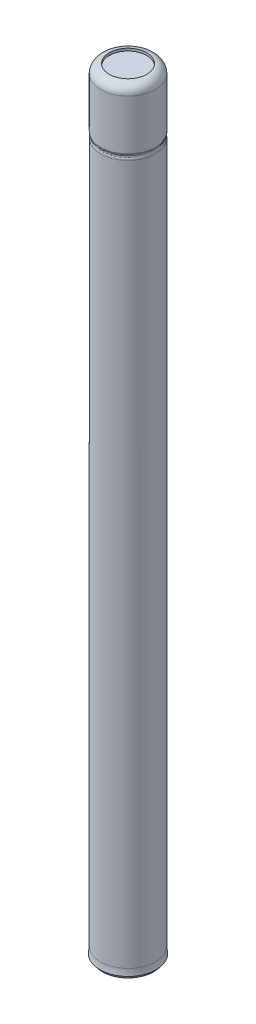
from build123d import *

# Parameters (mm, degrees)
FILLET1_R          = 3
FILLET2_R          = 0.75
SKETCH3_R          = 6.38
CUT_EXTRUDE1_DEPTH = 0.85


with BuildPart() as part:
    # Sketch2 → Revolve1 (revolve)
    with BuildSketch(Plane.XY):
        with BuildLine():
            Line((0, 263.525), (9.34, 263.525))
            Line((9.34, 263.525), (9.34, 243.380049267))
            Line((9.34, 243.380049267), (9.000677154, 242.525))
            Line((9.000677154, 242.525), (9.34, 241.669950733))
            Line((9.34, 241.669950733), (9.34, 3.410583034))
            ThreePointArc((9.34, 3.410583034), (9.391810091, 2.300465987), (9.546789941, 1.2))
            Line((9.546789941, 1.2), (9.000677154, 1.2))
            Line((9.000677154, 1.2), (9.000677154, 0))
            Line((9.000677154, 0), (0, 0))
            Line((0, 0), (0, 263.525))
        make_face()
    revolve(axis=Axis((0, 0, 0), (0, 1, 0)))

    # Fillet1
    fillet1_edges = [part.edges().sort_by_distance(p)[0] for p in [
        (-9.34, 263.525, 0),
    ]]
    fillet(fillet1_edges, radius=FILLET1_R)

    # Fillet2
    fillet2_edges = [part.edges().sort_by_distance(p)[0] for p in [
        (-9.000677154, 0, 0),
        (-9.34, 243.380049267, 0),
        (-9.000677154, 242.525, 0),
        (-9.34, 241.669950733, 0),
    ]]
    fillet(fillet2_edges, radius=FILLET2_R)

    # Sketch3 → Cut-Extrude1 (cut)
    with BuildSketch(Plane(origin=(0, 263.525, 0), x_dir=(1, 0, 0), z_dir=(0, 1, 0))):
        Circle(SKETCH3_R)
    extrude(amount=-CUT_EXTRUDE1_DEPTH, mode=Mode.SUBTRACT)


solid = part.part
